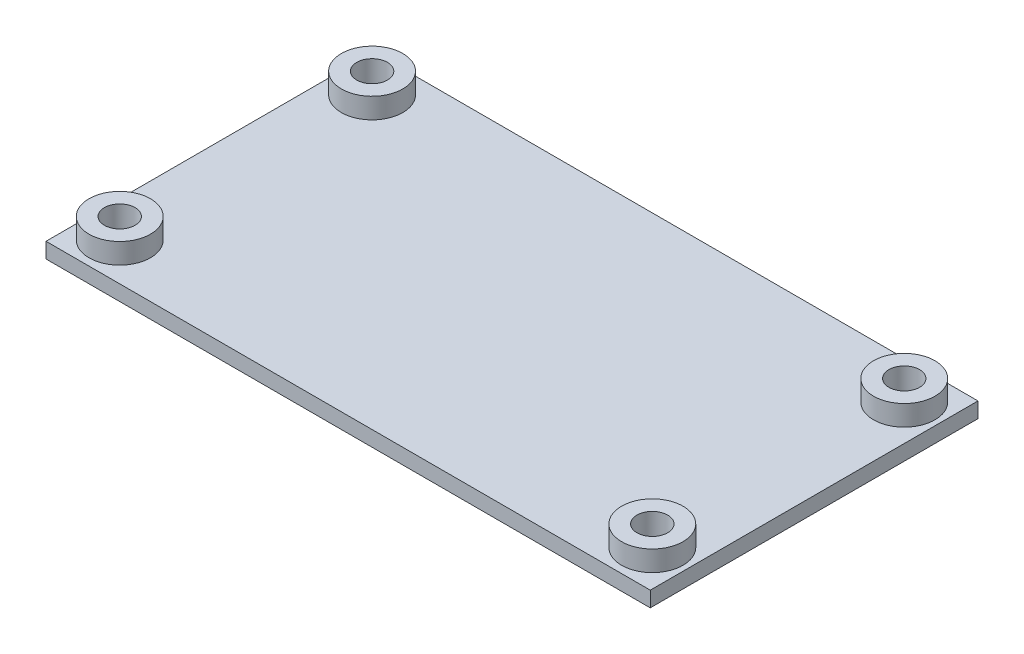
from build123d import *

# Parameters (mm, degrees)
SKETCH_2_W          = 57
SKETCH_2_H          = 40.4
EXTRUDE_1_DEPTH     = 1.5
SKETCH_4_R          = 3
SKETCH_4_R_2        = 1.5
EXTRUDE_3_DEPTH     = 4
SKETCH_5_W          = 57
SKETCH_5_H          = 4.2
CUT_EXTRUDE_1_DEPTH = 2.5
SKETCH_6_W          = 1
SKETCH_6_H          = 32
EXTRUDE_4_DEPTH     = 1.5
SKETCH_8_R          = 3
SKETCH_8_R_2        = 1.5
CUT_EXTRUDE_3_DEPTH = 2
SKETCH_7_R          = 1.5
CUT_EXTRUDE_4_DEPTH = 4.5


with BuildPart() as part:
    # 草图2 → 凸台-拉伸1 (new body)
    with BuildSketch(Plane(origin=(0, 0, 0), x_dir=(1, 0, 0), z_dir=(0, 1, 0))):
        with Locations((3.861898857, -4.534326193)):
            Rectangle(SKETCH_2_W, SKETCH_2_H)
    extrude(amount=EXTRUDE_1_DEPTH)

    # 草图4 → 凸台-拉伸3 (add)
    with BuildSketch(Plane(origin=(0, 1.5, 0), x_dir=(1, 0, 0), z_dir=(0, 1, 0))):
        with Locations((-22.099370277, 7.765673807)):
            Circle(SKETCH_4_R)
        with Locations((-22.099370277, 7.765673807)):
            Circle(SKETCH_4_R_2, mode=Mode.SUBTRACT)
        with Locations((-22.138101143, -16.834326193)):
            Circle(SKETCH_4_R)
        with Locations((-22.138101143, -16.834326193)):
            Circle(SKETCH_4_R_2, mode=Mode.SUBTRACT)
        with Locations((29.861898857, -16.834326193)):
            Circle(SKETCH_4_R)
        with Locations((29.861898857, -16.834326193)):
            Circle(SKETCH_4_R_2, mode=Mode.SUBTRACT)
        with Locations((29.861898857, 7.765673807)):
            Circle(SKETCH_4_R)
        with Locations((29.861898857, 7.765673807)):
            Circle(SKETCH_4_R_2, mode=Mode.SUBTRACT)
    extrude(amount=EXTRUDE_3_DEPTH)

    # 草图5 → 切除-拉伸1 (cut, through all)
    with BuildSketch(Plane(origin=(0, 1.5, 0), x_dir=(1, 0, 0), z_dir=(0, 1, 0))):
        with Locations((3.861898857, 13.565673807)):
            Rectangle(SKETCH_5_W, SKETCH_5_H)
        with Locations((3.861898857, -22.634326193)):
            Rectangle(SKETCH_5_W, SKETCH_5_H)
    extrude(amount=-CUT_EXTRUDE_1_DEPTH, mode=Mode.SUBTRACT)

    # 草图6 → 凸台-拉伸4 (add)
    with BuildSketch(Plane(origin=(0, 1.5, 0), x_dir=(1, 0, 0), z_dir=(0, 1, 0))):
        with Locations((-25.138101143, -4.534326193)):
            Rectangle(SKETCH_6_W, SKETCH_6_H)
        with Locations((32.861898857, -4.534326193)):
            Rectangle(SKETCH_6_W, SKETCH_6_H)
    extrude(amount=-EXTRUDE_4_DEPTH)

    # 草图8 → 切除-拉伸3 (cut)
    with BuildSketch(Plane(origin=(0, 5.5, 0), x_dir=(1, 0, 0), z_dir=(0, 1, 0))):
        with Locations((-22.138101143, -16.834326193)):
            Circle(SKETCH_8_R)
        with Locations((29.861898857, -16.834326193)):
            Circle(SKETCH_8_R)
        with Locations((29.861898857, -16.834326193)):
            Circle(SKETCH_8_R_2, mode=Mode.SUBTRACT)
        with Locations((29.861898857, 7.765673807)):
            Circle(SKETCH_8_R)
        with Locations((29.861898857, 7.765673807)):
            Circle(SKETCH_8_R_2, mode=Mode.SUBTRACT)
        with Locations((-22.099370277, 7.765673807)):
            Circle(SKETCH_8_R)
        with Locations((-22.099370277, 7.765673807)):
            Circle(SKETCH_8_R_2, mode=Mode.SUBTRACT)
    extrude(amount=-CUT_EXTRUDE_3_DEPTH, mode=Mode.SUBTRACT)

    # 草图7 → 切除-拉伸4 (cut, through all)
    with BuildSketch(Plane.XZ):
        with Locations((29.861898857, 16.834326193)):
            Circle(SKETCH_7_R)
        with Locations((29.861898857, -7.765673807)):
            Circle(SKETCH_7_R)
        with Locations((-22.099370277, -7.765673807)):
            Circle(SKETCH_7_R)
        with Locations((-22.138101143, 16.834326193)):
            Circle(SKETCH_7_R)
    extrude(amount=-CUT_EXTRUDE_4_DEPTH, mode=Mode.SUBTRACT)


solid = part.part
